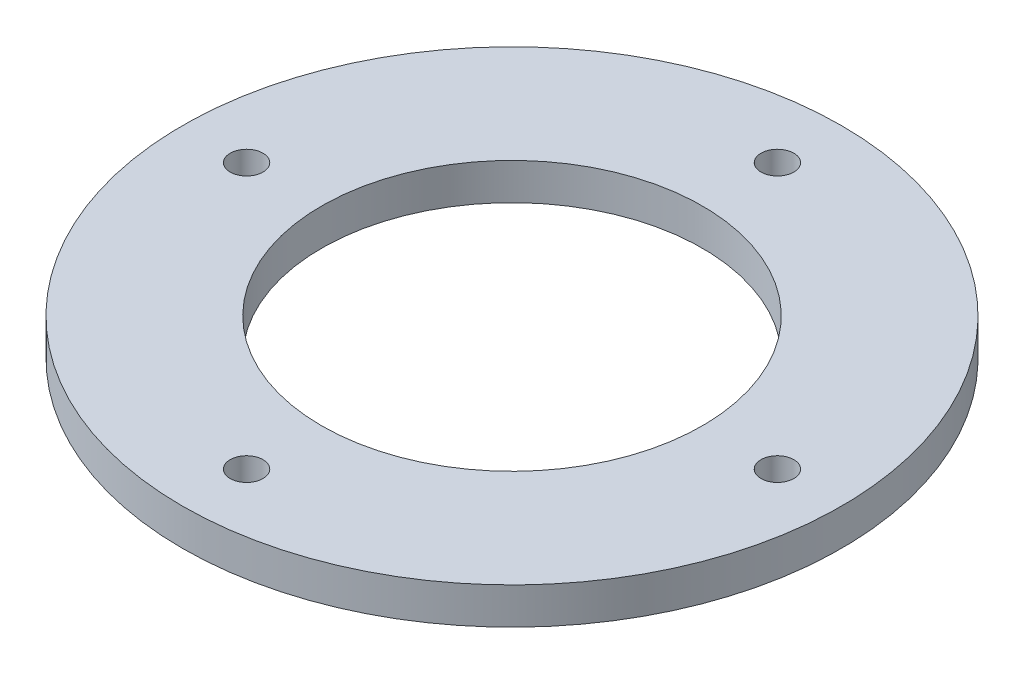
from build123d import *

# Parameters (mm, degrees)
SKETCH1_R           = 28.575
SKETCH1_R_2         = 16.51
SKETCH1_R_3         = 1.4224
BOSS_EXTRUDE1_DEPTH = 3.175


with BuildPart() as part:
    # Sketch1 → Boss-Extrude1 (new body)
    with BuildSketch(Plane(origin=(0, 0, 0), x_dir=(1, 0, 0), z_dir=(0, 1, 0))):
        Circle(SKETCH1_R)
        Circle(SKETCH1_R_2, mode=Mode.SUBTRACT)
        with Locations((23.0124, 0)):
            Circle(SKETCH1_R_3, mode=Mode.SUBTRACT)
        with Locations((0, -23.0124)):
            Circle(SKETCH1_R_3, mode=Mode.SUBTRACT)
        with Locations((-23.0124, 0)):
            Circle(SKETCH1_R_3, mode=Mode.SUBTRACT)
        with Locations((0, 23.0124)):
            Circle(SKETCH1_R_3, mode=Mode.SUBTRACT)
    extrude(amount=BOSS_EXTRUDE1_DEPTH)


solid = part.part
